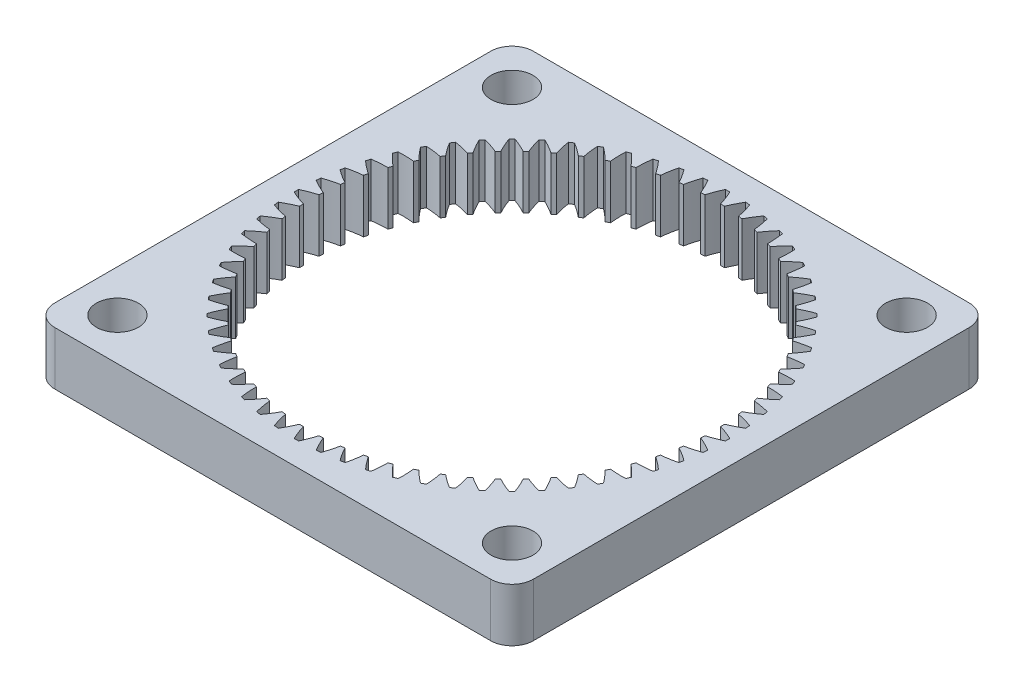
from build123d import *

# Parameters (mm, degrees)
SKETCH1_R           = 2.499995
BOSS_EXTRUDE1_DEPTH = 6.35


with BuildPart() as part:
    # Sketch1 → Boss-Extrude1 (new body)
    with BuildSketch(Plane(origin=(0, 0, 0), x_dir=(1, 0, 0), z_dir=(0, 1, 0))):
        with BuildLine():
            Line((-119.093527251, 26.784910593), (-119.093527251, 38.751589796))
            ThreePointArc((-119.093527251, 38.751589796), (-118.349578476, 40.54764102), (-116.553527251, 41.291589796))
            Line((-116.553527251, 41.291589796), (-104.586848048, 41.291589796))
            Line((-104.586848048, 41.291589796), (-76.600218855, 41.291589796))
            Line((-76.600218855, 41.291589796), (-64.633539651, 41.291589796))
            ThreePointArc((-64.633539651, 41.291589796), (-62.837488427, 40.54764102), (-62.093539651, 38.751589796))
            Line((-62.093539651, 38.751589796), (-62.093539651, 26.784910593))
            Line((-62.093539651, 26.784910593), (-62.093539651, -1.201718601))
            Line((-62.093539651, -1.201718601), (-62.093539651, -13.168397804))
            ThreePointArc((-62.093539651, -13.168397804), (-62.837488427, -14.964449028), (-64.633539651, -15.708397804))
            Line((-64.633539651, -15.708397804), (-76.600218855, -15.708397804))
            Line((-76.600218855, -15.708397804), (-104.586848048, -15.708397804))
            Line((-104.586848048, -15.708397804), (-116.553527251, -15.708397804))
            ThreePointArc((-116.553527251, -15.708397804), (-118.349578476, -14.964449028), (-119.093527251, -13.168397804))
            Line((-119.093527251, -13.168397804), (-119.093527251, -1.201718601))
            Line((-119.093527251, -1.201718601), (-119.093527251, 26.784910593))
        make_face()
        with Locations((-114.093537251, 36.291599796)):
            Circle(SKETCH1_R, mode=Mode.SUBTRACT)
        with Locations((-67.093529651, 36.291599796)):
            Circle(SKETCH1_R, mode=Mode.SUBTRACT)
        with Locations((-67.093529651, -10.708407804)):
            Circle(SKETCH1_R, mode=Mode.SUBTRACT)
        with Locations((-114.093537251, -10.708407804)):
            Circle(SKETCH1_R, mode=Mode.SUBTRACT)
        with BuildLine():
            ThreePointArc((-88.33476915, 38.37476739), (-88.790790028, 37.545930635), (-89.182049182, 36.684628317))
            ThreePointArc((-89.182049182, 36.684628317), (-89.419113984, 36.697453442), (-89.656294336, 36.707926488))
            ThreePointArc((-89.656294336, 36.707926488), (-89.961247081, 37.603431502), (-90.333831884, 38.472975045))
            ThreePointArc((-90.333831884, 38.472975045), (-90.593533451, 38.47428812), (-90.853235018, 38.472975045))
            ThreePointArc((-90.853235018, 38.472975045), (-91.225819822, 37.603431502), (-91.530772566, 36.707926488))
            ThreePointArc((-91.530772566, 36.707926488), (-91.767952919, 36.697453442), (-92.005017721, 36.684628317))
            ThreePointArc((-92.005017721, 36.684628317), (-92.396276875, 37.545930635), (-92.852297753, 38.37476739))
            ThreePointArc((-92.852297753, 38.37476739), (-93.110877489, 38.350618938), (-93.369199818, 38.32385698))
            ThreePointArc((-93.369199818, 38.32385698), (-93.654760353, 37.421980831), (-93.870469826, 36.500897321))
            ThreePointArc((-93.870469826, 36.500897321), (-94.105481552, 36.467226967), (-94.34014774, 36.431227184))
            ThreePointArc((-94.34014774, 36.431227184), (-94.813945265, 37.250031992), (-95.349010486, 38.03017981))
            ThreePointArc((-95.349010486, 38.03017981), (-95.603978128, 37.980802393), (-95.858433434, 37.928849285))
            ThreePointArc((-95.858433434, 37.928849285), (-96.054219596, 37.003326089), (-96.178608397, 36.065534623))
            ThreePointArc((-96.178608397, 36.065534623), (-96.409188205, 36.008991223), (-96.639195816, 35.95016348))
            ThreePointArc((-96.639195816, 35.95016348), (-97.190968782, 36.718585241), (-97.799925375, 37.44253087))
            ThreePointArc((-97.799925375, 37.44253087), (-98.048825446, 37.36840002), (-98.296963185, 37.291756099))
            ThreePointArc((-98.296963185, 37.291756099), (-98.401089445, 36.351499151), (-98.432959643, 35.406031172))
            ThreePointArc((-98.432959643, 35.406031172), (-98.656886924, 35.327159271), (-98.880020858, 35.246070111))
            ThreePointArc((-98.880020858, 35.246070111), (-99.50445539, 35.956708503), (-100.181438771, 36.617479953))
            ThreePointArc((-100.181438771, 36.617479953), (-100.421874226, 36.519309589), (-100.661304696, 36.418712979))
            ThreePointArc((-100.661304696, 36.418712979), (-100.672768263, 35.472777466), (-100.611812929, 34.528738348))
            ThreePointArc((-100.611812929, 34.528738348), (-100.826931141, 34.428297525), (-101.041042497, 34.325727882))
            ThreePointArc((-101.041042497, 34.325727882), (-101.732124948, 34.971739068), (-102.470615398, 35.562972748))
            ThreePointArc((-102.470615398, 35.562972748), (-102.700270712, 35.441708306), (-102.928688067, 35.318127806))
            ThreePointArc((-102.928688067, 35.318127806), (-102.847378539, 34.375623605), (-102.694184707, 33.442104961))
            ThreePointArc((-102.694184707, 33.442104961), (-102.898422144, 33.321062516), (-103.101448912, 33.198000191))
            ThreePointArc((-103.101448912, 33.198000191), (-103.852523782, 33.773162731), (-104.645409233, 34.289164737))
            ThreePointArc((-104.645409233, 34.289164737), (-104.862072699, 34.145974059), (-105.077277155, 34.000599817))
            ThreePointArc((-105.077277155, 34.000599817), (-104.903977589, 33.070603759), (-104.660020599, 32.156595884))
            ThreePointArc((-104.660020599, 32.156595884), (-104.851410343, 32.016117522), (-105.041397264, 31.873747672))
            ThreePointArc((-105.041397264, 31.873747672), (-105.84523129, 32.372522437), (-106.684875822, 32.808323387))
            ThreePointArc((-106.684875822, 32.808323387), (-106.886460854, 32.644585479), (-107.086379874, 32.478817527))
            ThreePointArc((-107.086379874, 32.478817527), (-106.822759239, 31.570285982), (-106.49038853, 30.684591272))
            ThreePointArc((-106.49038853, 30.684591272), (-106.667087393, 30.526029876), (-106.842204789, 30.365723601))
            ThreePointArc((-106.842204789, 30.365723601), (-107.691056611, 30.783307117), (-108.569373988, 31.134710011))
            ThreePointArc((-108.569373988, 31.134710011), (-108.753939212, 30.952001756), (-108.936647466, 30.767436532))
            ThreePointArc((-108.936647466, 30.767436532), (-108.585244572, 29.889119156), (-108.167661057, 29.040267334))
            ThreePointArc((-108.167661057, 29.040267334), (-108.327967331, 28.865149937), (-108.486528727, 28.688451075))
            ThreePointArc((-108.486528727, 28.688451075), (-109.372223438, 29.020821783), (-110.280754983, 29.284442419))
            ThreePointArc((-110.280754983, 29.284442419), (-110.446522934, 29.084523399), (-110.610260843, 28.882938367))
            ThreePointArc((-110.610260843, 28.882938367), (-110.174459892, 28.043293835), (-109.675685128, 27.239459808))
            ThreePointArc((-109.675685128, 27.239459808), (-109.818054977, 27.049472887), (-109.958533339, 26.858083144))
            ThreePointArc((-109.958533339, 26.858083144), (-110.872541214, 27.102040133), (-111.802537272, 27.2753397))
            ThreePointArc((-111.802537272, 27.2753397), (-111.947911515, 27.060135244), (-112.091102193, 26.843471777))
            ThreePointArc((-112.091102193, 26.843471777), (-111.575100187, 26.050586326), (-110.999937646, 25.299511457))
            ThreePointArc((-110.999937646, 25.299511457), (-111.122999971, 25.096484689), (-111.244042417, 24.892247252))
            ThreePointArc((-111.244042417, 24.892247252), (-112.17756106, 25.045441084), (-113.120065261, 25.126750611))
            ThreePointArc((-113.120065261, 25.126750611), (-113.243645762, 24.898333256), (-113.364910204, 24.668677942))
            ThreePointArc((-113.364910204, 24.668677942), (-112.773676524, 23.930187493), (-112.127665338, 23.239105041))
            ThreePointArc((-112.127665338, 23.239105041), (-112.230234981, 23.024993686), (-112.330675804, 22.809875473))
            ThreePointArc((-112.330675804, 22.809875473), (-113.274714921, 22.870830807), (-114.220650434, 22.85936724))
            ThreePointArc((-114.220650434, 22.85936724), (-114.321247045, 22.61993677), (-114.419417408, 22.379501316))
            ThreePointArc((-114.419417408, 22.379501316), (-113.758645958, 21.702517934), (-113.048007567, 21.078083403))
            ThreePointArc((-113.048007567, 21.078083403), (-113.129096726, 20.854949469), (-113.207968628, 20.631022187))
            ThreePointArc((-113.207968628, 20.631022187), (-114.153436606, 20.59915199), (-115.093693555, 20.495025729))
            ThreePointArc((-115.093693555, 20.495025729), (-115.170337475, 20.24688799), (-115.244468326, 19.99798792))
            ThreePointArc((-115.244468326, 19.99798792), (-114.520522696, 19.389031326), (-113.752100936, 18.83725836))
            ThreePointArc((-113.752100936, 18.83725836), (-113.810928678, 18.60725075), (-113.867472078, 18.376670941))
            ThreePointArc((-113.867472078, 18.376670941), (-114.805263544, 18.25228214), (-115.730786741, 18.056495979))
            ThreePointArc((-115.730786741, 18.056495979), (-115.782739848, 17.802040673), (-115.832117265, 17.54707303))
            ThreePointArc((-115.832117265, 17.54707303), (-115.051969448, 17.012007809), (-114.23316464, 16.538210285))
            ThreePointArc((-114.23316464, 16.538210285), (-114.269164423, 16.303544097), (-114.302834777, 16.06853237))
            ThreePointArc((-114.302834777, 16.06853237), (-115.223918286, 15.852822898), (-116.125794436, 15.567262363))
            ThreePointArc((-116.125794436, 15.567262363), (-116.152556393, 15.308940034), (-116.176704846, 15.050360297))
            ThreePointArc((-116.176704846, 15.050360297), (-115.34786809, 14.59433942), (-114.486565773, 14.203080265))
            ThreePointArc((-114.486565773, 14.203080265), (-114.499390898, 13.966015463), (-114.509863943, 13.728835111))
            ThreePointArc((-114.509863943, 13.728835111), (-115.405368958, 13.423882367), (-116.2749125, 13.051297563))
            ThreePointArc((-116.2749125, 13.051297563), (-116.276225576, 12.791595996), (-116.2749125, 12.531894429))
            ThreePointArc((-116.2749125, 12.531894429), (-115.405368958, 12.159309625), (-114.509863943, 11.854356881))
            ThreePointArc((-114.509863943, 11.854356881), (-114.499390898, 11.617176529), (-114.486565773, 11.380111726))
            ThreePointArc((-114.486565773, 11.380111726), (-115.34786809, 10.988852572), (-116.176704846, 10.532831695))
            ThreePointArc((-116.176704846, 10.532831695), (-116.152556393, 10.274251958), (-116.125794436, 10.015929629))
            ThreePointArc((-116.125794436, 10.015929629), (-115.223918286, 9.730369094), (-114.302834777, 9.514659621))
            ThreePointArc((-114.302834777, 9.514659621), (-114.269164423, 9.279647895), (-114.23316464, 9.044981707))
            ThreePointArc((-114.23316464, 9.044981707), (-115.051969448, 8.571184182), (-115.832117265, 8.036118962))
            ThreePointArc((-115.832117265, 8.036118962), (-115.782739848, 7.781151319), (-115.730786741, 7.526696013))
            ThreePointArc((-115.730786741, 7.526696013), (-114.805263544, 7.330909852), (-113.867472078, 7.206521051))
            ThreePointArc((-113.867472078, 7.206521051), (-113.810928678, 6.975941242), (-113.752100936, 6.745933631))
            ThreePointArc((-113.752100936, 6.745933631), (-114.520522696, 6.194160666), (-115.244468326, 5.585204072))
            ThreePointArc((-115.244468326, 5.585204072), (-115.170337475, 5.336304002), (-115.093693555, 5.088166263))
            ThreePointArc((-115.093693555, 5.088166263), (-114.153436606, 4.984040002), (-113.207968628, 4.952169805))
            ThreePointArc((-113.207968628, 4.952169805), (-113.129096726, 4.728242523), (-113.048007567, 4.505108589))
            ThreePointArc((-113.048007567, 4.505108589), (-113.758645958, 3.880674058), (-114.419417408, 3.203690676))
            ThreePointArc((-114.419417408, 3.203690676), (-114.321247045, 2.963255221), (-114.220650434, 2.723824751))
            ThreePointArc((-114.220650434, 2.723824751), (-113.274714921, 2.712361185), (-112.330675804, 2.773316518))
            ThreePointArc((-112.330675804, 2.773316518), (-112.230234981, 2.558198306), (-112.127665338, 2.344086951))
            ThreePointArc((-112.127665338, 2.344086951), (-112.773676524, 1.653004499), (-113.364910204, 0.914514049))
            ThreePointArc((-113.364910204, 0.914514049), (-113.243645762, 0.684858736), (-113.120065261, 0.456441381))
            ThreePointArc((-113.120065261, 0.456441381), (-112.17756106, 0.537750908), (-111.244042417, 0.69094474))
            ThreePointArc((-111.244042417, 0.69094474), (-111.122999971, 0.486707303), (-110.999937646, 0.283680535))
            ThreePointArc((-110.999937646, 0.283680535), (-111.575100187, -0.467394335), (-112.091102193, -1.260279785))
            ThreePointArc((-112.091102193, -1.260279785), (-111.947911515, -1.476943252), (-111.802537272, -1.692147708))
            ThreePointArc((-111.802537272, -1.692147708), (-110.872541214, -1.518848142), (-109.958533339, -1.274891152))
            ThreePointArc((-109.958533339, -1.274891152), (-109.818054977, -1.466280895), (-109.675685128, -1.656267817))
            ThreePointArc((-109.675685128, -1.656267817), (-110.174459892, -2.460101843), (-110.610260843, -3.299746375))
            ThreePointArc((-110.610260843, -3.299746375), (-110.446522934, -3.501331407), (-110.280754983, -3.701250427))
            ThreePointArc((-110.280754983, -3.701250427), (-109.372223438, -3.437629791), (-108.486528727, -3.105259083))
            ThreePointArc((-108.486528727, -3.105259083), (-108.327967331, -3.281957945), (-108.167661057, -3.457075342))
            ThreePointArc((-108.167661057, -3.457075342), (-108.585244572, -4.305927164), (-108.936647466, -5.184244541))
            ThreePointArc((-108.936647466, -5.184244541), (-108.753939212, -5.368809764), (-108.569373988, -5.551518019))
            ThreePointArc((-108.569373988, -5.551518019), (-107.691056611, -5.200115125), (-106.842204789, -4.78253161))
            ThreePointArc((-106.842204789, -4.78253161), (-106.667087393, -4.942837884), (-106.49038853, -5.10139928))
            ThreePointArc((-106.49038853, -5.10139928), (-106.822759239, -5.987093991), (-107.086379874, -6.895625536))
            ThreePointArc((-107.086379874, -6.895625536), (-106.886460854, -7.061393487), (-106.684875822, -7.225131396))
            ThreePointArc((-106.684875822, -7.225131396), (-105.84523129, -6.789330445), (-105.041397264, -6.29055568))
            ThreePointArc((-105.041397264, -6.29055568), (-104.851410343, -6.43292553), (-104.660020599, -6.573403892))
            ThreePointArc((-104.660020599, -6.573403892), (-104.903977589, -7.487411767), (-105.077277155, -8.417407825))
            ThreePointArc((-105.077277155, -8.417407825), (-104.862072699, -8.562782068), (-104.645409233, -8.705972745))
            ThreePointArc((-104.645409233, -8.705972745), (-103.852523782, -8.189970739), (-103.101448912, -7.614808199))
            ThreePointArc((-103.101448912, -7.614808199), (-102.898422144, -7.737870524), (-102.694184707, -7.858912969))
            ThreePointArc((-102.694184707, -7.858912969), (-102.847378539, -8.792431613), (-102.928688067, -9.734935814))
            ThreePointArc((-102.928688067, -9.734935814), (-102.700270712, -9.858516314), (-102.470615398, -9.979780756))
            ThreePointArc((-102.470615398, -9.979780756), (-101.732124948, -9.388547077), (-101.041042497, -8.74253589))
            ThreePointArc((-101.041042497, -8.74253589), (-100.826931141, -8.845105533), (-100.611812929, -8.945546357))
            ThreePointArc((-100.611812929, -8.945546357), (-100.672768263, -9.889585474), (-100.661304696, -10.835520987))
            ThreePointArc((-100.661304696, -10.835520987), (-100.421874226, -10.936117598), (-100.181438771, -11.034287961))
            ThreePointArc((-100.181438771, -11.034287961), (-99.50445539, -10.373516511), (-98.880020858, -9.66287812))
            ThreePointArc((-98.880020858, -9.66287812), (-98.656886924, -9.743967279), (-98.432959643, -9.82283918))
            ThreePointArc((-98.432959643, -9.82283918), (-98.401089445, -10.768307159), (-98.296963185, -11.708564108))
            ThreePointArc((-98.296963185, -11.708564108), (-98.048825446, -11.785208028), (-97.799925375, -11.859338879))
            ThreePointArc((-97.799925375, -11.859338879), (-97.190968782, -11.135393249), (-96.639195816, -10.366971488))
            ThreePointArc((-96.639195816, -10.366971488), (-96.409188205, -10.425799231), (-96.178608397, -10.482342631))
            ThreePointArc((-96.178608397, -10.482342631), (-96.054219596, -11.420134097), (-95.858433434, -12.345657293))
            ThreePointArc((-95.858433434, -12.345657293), (-95.603978128, -12.397610401), (-95.349010486, -12.446987818))
            ThreePointArc((-95.349010486, -12.446987818), (-94.813945265, -11.66684), (-94.34014774, -10.848035192))
            ThreePointArc((-94.34014774, -10.848035192), (-94.105481552, -10.884034975), (-93.870469826, -10.91770533))
            ThreePointArc((-93.870469826, -10.91770533), (-93.654760353, -11.838788839), (-93.369199818, -12.740664988))
            ThreePointArc((-93.369199818, -12.740664988), (-93.110877489, -12.767426946), (-92.852297753, -12.791575398))
            ThreePointArc((-92.852297753, -12.791575398), (-92.396276875, -11.962738643), (-92.005017721, -11.101436325))
            ThreePointArc((-92.005017721, -11.101436325), (-91.767952919, -11.114261451), (-91.530772566, -11.124734496))
            ThreePointArc((-91.530772566, -11.124734496), (-91.225819822, -12.020239511), (-90.853235018, -12.889783053))
            ThreePointArc((-90.853235018, -12.889783053), (-90.593533451, -12.891096128), (-90.333831884, -12.889783053))
            ThreePointArc((-90.333831884, -12.889783053), (-89.961247081, -12.020239511), (-89.656294336, -11.124734496))
            ThreePointArc((-89.656294336, -11.124734496), (-89.419113984, -11.114261451), (-89.182049182, -11.101436325))
            ThreePointArc((-89.182049182, -11.101436325), (-88.790790028, -11.962738643), (-88.33476915, -12.791575398))
            ThreePointArc((-88.33476915, -12.791575398), (-88.076189413, -12.767426946), (-87.817867084, -12.740664988))
            ThreePointArc((-87.817867084, -12.740664988), (-87.53230655, -11.838788839), (-87.316597077, -10.91770533))
            ThreePointArc((-87.316597077, -10.91770533), (-87.081585351, -10.884034975), (-86.846919163, -10.848035192))
            ThreePointArc((-86.846919163, -10.848035192), (-86.373121638, -11.66684), (-85.838056417, -12.446987818))
            ThreePointArc((-85.838056417, -12.446987818), (-85.583088775, -12.397610401), (-85.328633469, -12.345657293))
            ThreePointArc((-85.328633469, -12.345657293), (-85.132847307, -11.420134097), (-85.008458506, -10.482342631))
            ThreePointArc((-85.008458506, -10.482342631), (-84.777878697, -10.425799231), (-84.547871087, -10.366971488))
            ThreePointArc((-84.547871087, -10.366971488), (-83.996098121, -11.135393249), (-83.387141527, -11.859338879))
            ThreePointArc((-83.387141527, -11.859338879), (-83.138241457, -11.785208028), (-82.890103718, -11.708564108))
            ThreePointArc((-82.890103718, -11.708564108), (-82.785977458, -10.768307159), (-82.75410726, -9.82283918))
            ThreePointArc((-82.75410726, -9.82283918), (-82.530179979, -9.743967279), (-82.307046045, -9.66287812))
            ThreePointArc((-82.307046045, -9.66287812), (-81.682611513, -10.373516511), (-81.005628131, -11.034287961))
            ThreePointArc((-81.005628131, -11.034287961), (-80.765192677, -10.936117598), (-80.525762207, -10.835520987))
            ThreePointArc((-80.525762207, -10.835520987), (-80.51429864, -9.889585474), (-80.575253974, -8.945546357))
            ThreePointArc((-80.575253974, -8.945546357), (-80.360135762, -8.845105533), (-80.146024406, -8.74253589))
            ThreePointArc((-80.146024406, -8.74253589), (-79.454941954, -9.388547077), (-78.716451505, -9.979780756))
            ThreePointArc((-78.716451505, -9.979780756), (-78.486796191, -9.858516314), (-78.258378836, -9.734935814))
            ThreePointArc((-78.258378836, -9.734935814), (-78.339688364, -8.792431613), (-78.492882196, -7.858912969))
            ThreePointArc((-78.492882196, -7.858912969), (-78.288644759, -7.737870524), (-78.085617991, -7.614808199))
            ThreePointArc((-78.085617991, -7.614808199), (-77.334543121, -8.189970739), (-76.54165767, -8.705972745))
            ThreePointArc((-76.54165767, -8.705972745), (-76.324994203, -8.562782068), (-76.109789748, -8.417407825))
            ThreePointArc((-76.109789748, -8.417407825), (-76.283089314, -7.487411767), (-76.527046304, -6.573403892))
            ThreePointArc((-76.527046304, -6.573403892), (-76.33565656, -6.43292553), (-76.145669639, -6.29055568))
            ThreePointArc((-76.145669639, -6.29055568), (-75.341835612, -6.789330445), (-74.502191081, -7.225131396))
            ThreePointArc((-74.502191081, -7.225131396), (-74.300606049, -7.061393487), (-74.100687029, -6.895625536))
            ThreePointArc((-74.100687029, -6.895625536), (-74.364307664, -5.987093991), (-74.696678373, -5.10139928))
            ThreePointArc((-74.696678373, -5.10139928), (-74.51997951, -4.942837884), (-74.344862114, -4.78253161))
            ThreePointArc((-74.344862114, -4.78253161), (-73.496010291, -5.200115125), (-72.617692915, -5.551518019))
            ThreePointArc((-72.617692915, -5.551518019), (-72.433127691, -5.368809764), (-72.250419437, -5.184244541))
            ThreePointArc((-72.250419437, -5.184244541), (-72.601822331, -4.305927164), (-73.019405846, -3.457075342))
            ThreePointArc((-73.019405846, -3.457075342), (-72.859099572, -3.281957945), (-72.700538176, -3.105259083))
            ThreePointArc((-72.700538176, -3.105259083), (-71.814843465, -3.437629791), (-70.90631192, -3.701250427))
            ThreePointArc((-70.90631192, -3.701250427), (-70.740543969, -3.501331407), (-70.57680606, -3.299746375))
            ThreePointArc((-70.57680606, -3.299746375), (-71.012607011, -2.460101843), (-71.511381775, -1.656267817))
            ThreePointArc((-71.511381775, -1.656267817), (-71.369011926, -1.466280895), (-71.228533563, -1.274891152))
            ThreePointArc((-71.228533563, -1.274891152), (-70.314525689, -1.518848142), (-69.38452963, -1.692147708))
            ThreePointArc((-69.38452963, -1.692147708), (-69.239155388, -1.476943252), (-69.09596471, -1.260279785))
            ThreePointArc((-69.09596471, -1.260279785), (-69.611966716, -0.467394335), (-70.187129256, 0.283680535))
            ThreePointArc((-70.187129256, 0.283680535), (-70.064066931, 0.486707303), (-69.943024486, 0.69094474))
            ThreePointArc((-69.943024486, 0.69094474), (-69.009505843, 0.537750908), (-68.067001642, 0.456441381))
            ThreePointArc((-68.067001642, 0.456441381), (-67.943421141, 0.684858736), (-67.822156699, 0.914514049))
            ThreePointArc((-67.822156699, 0.914514049), (-68.413390379, 1.653004499), (-69.059401565, 2.344086951))
            ThreePointArc((-69.059401565, 2.344086951), (-68.956831922, 2.558198306), (-68.856391099, 2.773316518))
            ThreePointArc((-68.856391099, 2.773316518), (-67.912351982, 2.712361185), (-66.966416469, 2.723824751))
            ThreePointArc((-66.966416469, 2.723824751), (-66.865819858, 2.963255221), (-66.767649495, 3.203690676))
            ThreePointArc((-66.767649495, 3.203690676), (-67.428420944, 3.880674058), (-68.139059336, 4.505108589))
            ThreePointArc((-68.139059336, 4.505108589), (-68.057970177, 4.728242523), (-67.979098275, 4.952169805))
            ThreePointArc((-67.979098275, 4.952169805), (-67.033630297, 4.984040002), (-66.093373348, 5.088166263))
            ThreePointArc((-66.093373348, 5.088166263), (-66.016729427, 5.336304002), (-65.942598577, 5.585204072))
            ThreePointArc((-65.942598577, 5.585204072), (-66.666544207, 6.194160666), (-67.434965967, 6.745933631))
            ThreePointArc((-67.434965967, 6.745933631), (-67.376138224, 6.975941242), (-67.319594825, 7.206521051))
            ThreePointArc((-67.319594825, 7.206521051), (-66.381803359, 7.330909852), (-65.456280162, 7.526696013))
            ThreePointArc((-65.456280162, 7.526696013), (-65.404327055, 7.781151319), (-65.354949638, 8.036118962))
            ThreePointArc((-65.354949638, 8.036118962), (-66.135097455, 8.571184182), (-66.953902263, 9.044981707))
            ThreePointArc((-66.953902263, 9.044981707), (-66.91790248, 9.279647895), (-66.884232126, 9.514659621))
            ThreePointArc((-66.884232126, 9.514659621), (-65.963148617, 9.730369094), (-65.061272467, 10.015929629))
            ThreePointArc((-65.061272467, 10.015929629), (-65.034510509, 10.274251958), (-65.010362057, 10.532831695))
            ThreePointArc((-65.010362057, 10.532831695), (-65.839198813, 10.988852572), (-66.70050113, 11.380111726))
            ThreePointArc((-66.70050113, 11.380111726), (-66.687676005, 11.617176529), (-66.67720296, 11.854356881))
            ThreePointArc((-66.67720296, 11.854356881), (-65.781697945, 12.159309625), (-64.912154403, 12.531894429))
            ThreePointArc((-64.912154403, 12.531894429), (-64.910841327, 12.791595996), (-64.912154403, 13.051297563))
            ThreePointArc((-64.912154403, 13.051297563), (-65.781697945, 13.423882367), (-66.67720296, 13.728835111))
            ThreePointArc((-66.67720296, 13.728835111), (-66.687676005, 13.966015463), (-66.70050113, 14.203080265))
            ThreePointArc((-66.70050113, 14.203080265), (-65.839198813, 14.59433942), (-65.010362057, 15.050360297))
            ThreePointArc((-65.010362057, 15.050360297), (-65.034510509, 15.308940034), (-65.061272467, 15.567262363))
            ThreePointArc((-65.061272467, 15.567262363), (-65.963148617, 15.852822898), (-66.884232126, 16.06853237))
            ThreePointArc((-66.884232126, 16.06853237), (-66.91790248, 16.303544097), (-66.953902263, 16.538210285))
            ThreePointArc((-66.953902263, 16.538210285), (-66.135097455, 17.012007809), (-65.354949638, 17.54707303))
            ThreePointArc((-65.354949638, 17.54707303), (-65.404327055, 17.802040673), (-65.456280162, 18.056495979))
            ThreePointArc((-65.456280162, 18.056495979), (-66.381803359, 18.25228214), (-67.319594825, 18.376670941))
            ThreePointArc((-67.319594825, 18.376670941), (-67.376138224, 18.60725075), (-67.434965967, 18.83725836))
            ThreePointArc((-67.434965967, 18.83725836), (-66.666544207, 19.389031326), (-65.942598577, 19.99798792))
            ThreePointArc((-65.942598577, 19.99798792), (-66.016729427, 20.24688799), (-66.093373348, 20.495025729))
            ThreePointArc((-66.093373348, 20.495025729), (-67.033630297, 20.59915199), (-67.979098275, 20.631022187))
            ThreePointArc((-67.979098275, 20.631022187), (-68.057970177, 20.854949469), (-68.139059336, 21.078083403))
            ThreePointArc((-68.139059336, 21.078083403), (-67.428420944, 21.702517934), (-66.767649495, 22.379501316))
            ThreePointArc((-66.767649495, 22.379501316), (-66.865819858, 22.61993677), (-66.966416469, 22.85936724))
            ThreePointArc((-66.966416469, 22.85936724), (-67.912351982, 22.870830807), (-68.856391099, 22.809875473))
            ThreePointArc((-68.856391099, 22.809875473), (-68.956831922, 23.024993686), (-69.059401565, 23.239105041))
            ThreePointArc((-69.059401565, 23.239105041), (-68.413390379, 23.930187493), (-67.822156699, 24.668677942))
            ThreePointArc((-67.822156699, 24.668677942), (-67.943421141, 24.898333256), (-68.067001642, 25.126750611))
            ThreePointArc((-68.067001642, 25.126750611), (-69.009505843, 25.045441084), (-69.943024486, 24.892247252))
            ThreePointArc((-69.943024486, 24.892247252), (-70.064066931, 25.096484689), (-70.187129256, 25.299511457))
            ThreePointArc((-70.187129256, 25.299511457), (-69.611966716, 26.050586326), (-69.09596471, 26.843471777))
            ThreePointArc((-69.09596471, 26.843471777), (-69.239155388, 27.060135244), (-69.38452963, 27.2753397))
            ThreePointArc((-69.38452963, 27.2753397), (-70.314525689, 27.102040133), (-71.228533563, 26.858083144))
            ThreePointArc((-71.228533563, 26.858083144), (-71.369011926, 27.049472887), (-71.511381775, 27.239459808))
            ThreePointArc((-71.511381775, 27.239459808), (-71.012607011, 28.043293835), (-70.57680606, 28.882938367))
            ThreePointArc((-70.57680606, 28.882938367), (-70.740543969, 29.084523399), (-70.90631192, 29.284442419))
            ThreePointArc((-70.90631192, 29.284442419), (-71.814843465, 29.020821783), (-72.700538176, 28.688451075))
            ThreePointArc((-72.700538176, 28.688451075), (-72.859099572, 28.865149937), (-73.019405846, 29.040267334))
            ThreePointArc((-73.019405846, 29.040267334), (-72.601822331, 29.889119156), (-72.250419437, 30.767436532))
            ThreePointArc((-72.250419437, 30.767436532), (-72.433127691, 30.952001756), (-72.617692915, 31.134710011))
            ThreePointArc((-72.617692915, 31.134710011), (-73.496010291, 30.783307117), (-74.344862114, 30.365723601))
            ThreePointArc((-74.344862114, 30.365723601), (-74.51997951, 30.526029876), (-74.696678373, 30.684591272))
            ThreePointArc((-74.696678373, 30.684591272), (-74.364307664, 31.570285982), (-74.100687029, 32.478817527))
            ThreePointArc((-74.100687029, 32.478817527), (-74.300606049, 32.644585479), (-74.502191081, 32.808323387))
            ThreePointArc((-74.502191081, 32.808323387), (-75.341835612, 32.372522437), (-76.145669639, 31.873747672))
            ThreePointArc((-76.145669639, 31.873747672), (-76.33565656, 32.016117522), (-76.527046304, 32.156595884))
            ThreePointArc((-76.527046304, 32.156595884), (-76.283089314, 33.070603759), (-76.109789748, 34.000599817))
            ThreePointArc((-76.109789748, 34.000599817), (-76.324994203, 34.145974059), (-76.54165767, 34.289164737))
            ThreePointArc((-76.54165767, 34.289164737), (-77.334543121, 33.773162731), (-78.085617991, 33.198000191))
            ThreePointArc((-78.085617991, 33.198000191), (-78.288644759, 33.321062516), (-78.492882196, 33.442104961))
            ThreePointArc((-78.492882196, 33.442104961), (-78.339688364, 34.375623605), (-78.258378836, 35.318127806))
            ThreePointArc((-78.258378836, 35.318127806), (-78.486796191, 35.441708306), (-78.716451505, 35.562972748))
            ThreePointArc((-78.716451505, 35.562972748), (-79.454941954, 34.971739068), (-80.146024406, 34.325727882))
            ThreePointArc((-80.146024406, 34.325727882), (-80.360135762, 34.428297525), (-80.575253974, 34.528738348))
            ThreePointArc((-80.575253974, 34.528738348), (-80.51429864, 35.472777466), (-80.525762207, 36.418712979))
            ThreePointArc((-80.525762207, 36.418712979), (-80.765192677, 36.519309589), (-81.005628131, 36.617479953))
            ThreePointArc((-81.005628131, 36.617479953), (-81.682611513, 35.956708503), (-82.307046045, 35.246070111))
            ThreePointArc((-82.307046045, 35.246070111), (-82.530179979, 35.327159271), (-82.75410726, 35.406031172))
            ThreePointArc((-82.75410726, 35.406031172), (-82.785977458, 36.351499151), (-82.890103718, 37.291756099))
            ThreePointArc((-82.890103718, 37.291756099), (-83.138241457, 37.36840002), (-83.387141527, 37.44253087))
            ThreePointArc((-83.387141527, 37.44253087), (-83.996098121, 36.718585241), (-84.547871087, 35.95016348))
            ThreePointArc((-84.547871087, 35.95016348), (-84.777878697, 36.008991223), (-85.008458506, 36.065534623))
            ThreePointArc((-85.008458506, 36.065534623), (-85.132847307, 37.003326089), (-85.328633469, 37.928849285))
            ThreePointArc((-85.328633469, 37.928849285), (-85.583088775, 37.980802393), (-85.838056417, 38.03017981))
            ThreePointArc((-85.838056417, 38.03017981), (-86.373121638, 37.250031992), (-86.846919163, 36.431227184))
            ThreePointArc((-86.846919163, 36.431227184), (-87.081585351, 36.467226967), (-87.316597077, 36.500897321))
            ThreePointArc((-87.316597077, 36.500897321), (-87.53230655, 37.421980831), (-87.817867084, 38.32385698))
            ThreePointArc((-87.817867084, 38.32385698), (-88.076189413, 38.350618938), (-88.33476915, 38.37476739))
        make_face(mode=Mode.SUBTRACT)
    extrude(amount=BOSS_EXTRUDE1_DEPTH)


solid = part.part
